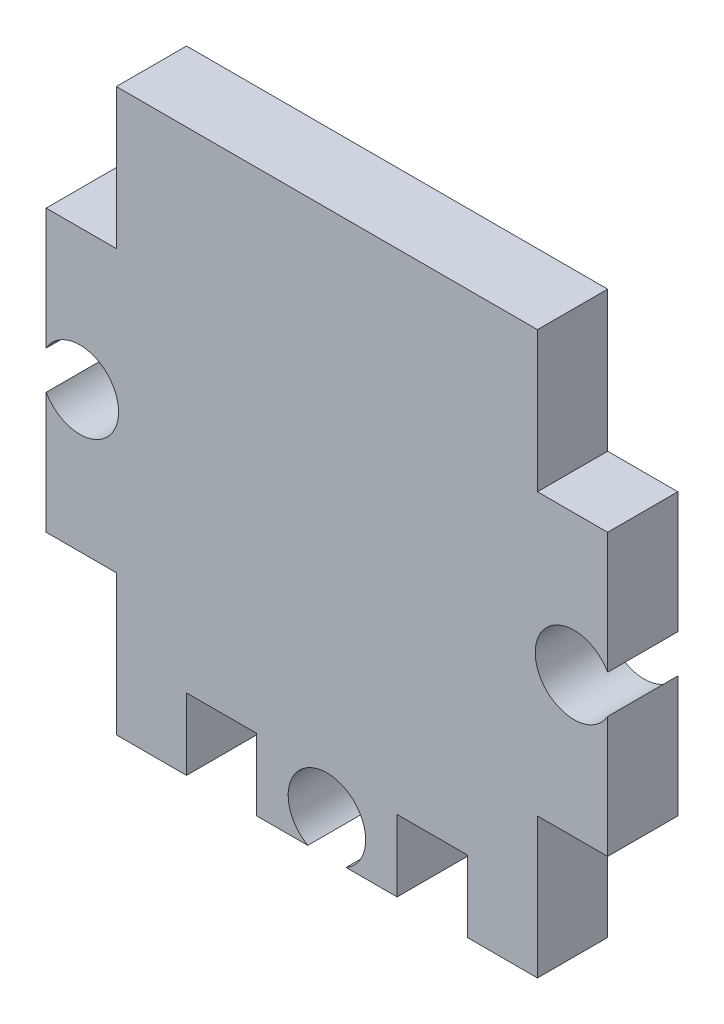
from build123d import *

# Parameters (mm, degrees)
BOSS_EXTRUDE1_DEPTH = 3.175


with BuildPart() as part:
    # Sketch1 → Boss-Extrude1 (new body)
    with BuildSketch(Plane.XY):
        with BuildLine():
            Line((-9.525, 12.7), (9.525, 12.7))
            Line((9.525, 12.7), (9.525, 6.35))
            Line((9.525, 6.35), (12.7, 6.35))
            Line((12.7, 6.35), (12.7, 0.865465632))
            ThreePointArc((12.7, 0.865465632), (9.4234, 0), (12.7, -0.865465632))
            Line((12.7, -0.865465632), (12.7, -6.35))
            Line((12.7, -6.35), (9.525, -6.35))
            Line((9.525, -6.35), (9.525, -12.7))
            Line((9.525, -12.7), (6.35, -12.7))
            Line((6.35, -12.7), (6.35, -9.467093743))
            Line((6.35, -9.467093743), (3.175, -9.467093743))
            Line((3.175, -9.467093743), (3.175, -12.7))
            Line((3.175, -12.7), (0.865465632, -12.7))
            ThreePointArc((0.865465632, -12.7), (0, -9.4234), (-0.865465632, -12.7))
            Line((-0.865465632, -12.7), (-3.175, -12.7))
            Line((-3.175, -12.7), (-3.175, -9.467093743))
            Line((-3.175, -9.467093743), (-6.35, -9.467093743))
            Line((-6.35, -9.467093743), (-6.35, -12.7))
            Line((-6.35, -12.7), (-9.525, -12.7))
            Line((-9.525, -12.7), (-9.525, -6.35))
            Line((-9.525, -6.35), (-12.7, -6.35))
            Line((-12.7, -6.35), (-12.7, -0.865465632))
            ThreePointArc((-12.7, -0.865465632), (-9.4234, 0), (-12.7, 0.865465632))
            Line((-12.7, 0.865465632), (-12.7, 6.35))
            Line((-12.7, 6.35), (-9.525, 6.35))
            Line((-9.525, 6.35), (-9.525, 12.7))
        make_face()
    extrude(amount=BOSS_EXTRUDE1_DEPTH)


solid = part.part
